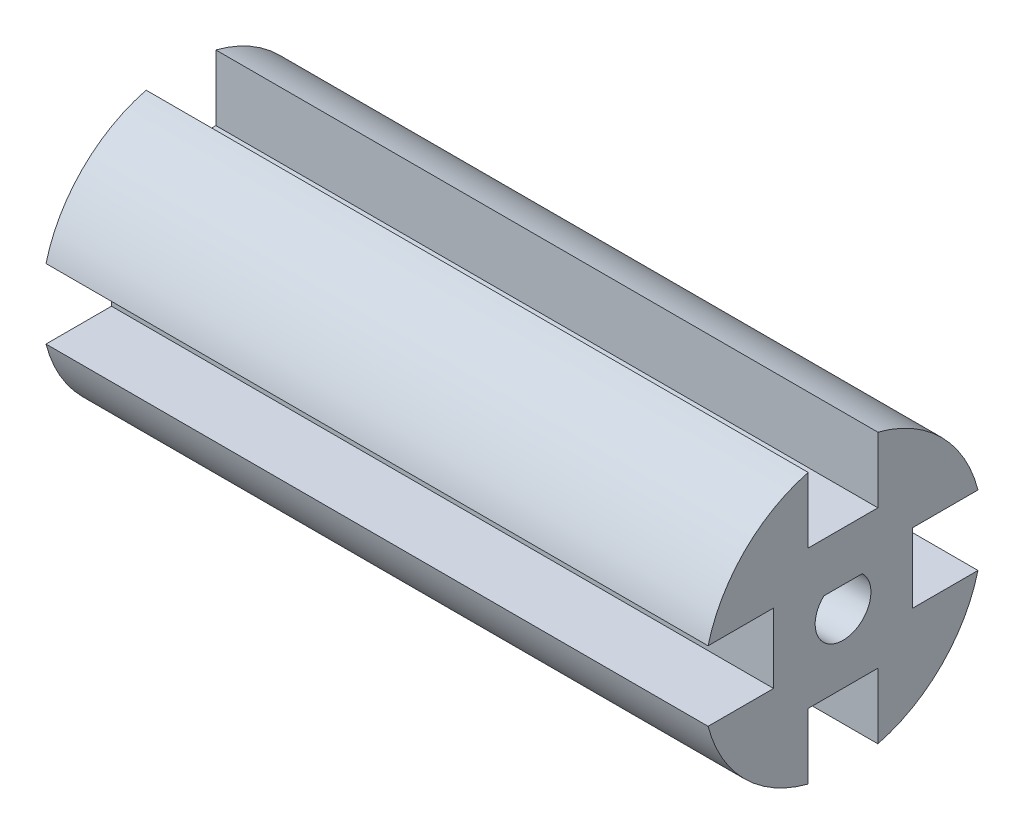
from build123d import *

# Parameters (mm, degrees)
EXTRUDED_CONNECTOR_DEPTH = 95
KEY_CUT_DEPTH            = 20


with BuildPart() as part:
    # Sketch1 → Extruded Connector (new body)
    with BuildSketch(Plane(origin=(0, 0, 0), x_dir=(0, 0, -1), z_dir=(1, 0, 0))):
        with BuildLine():
            ThreePointArc((-19.364916731, -5), (-14.142135624, -14.142135624), (-5, -19.364916731))
            Line((-5, -19.364916731), (-5, -9.964916731))
            Line((-5, -9.964916731), (5, -9.964916731))
            Line((5, -9.964916731), (5, -19.364916731))
            ThreePointArc((5, -19.364916731), (14.142135624, -14.142135624), (19.364916731, -5))
            Line((19.364916731, -5), (9.964916731, -5))
            Line((9.964916731, -5), (9.964916731, 5))
            Line((9.964916731, 5), (19.364916731, 5))
            ThreePointArc((19.364916731, 5), (14.142135624, 14.142135624), (5, 19.364916731))
            Line((5, 19.364916731), (5, 9.964916731))
            Line((5, 9.964916731), (-5, 9.964916731))
            Line((-5, 9.964916731), (-5, 19.364916731))
            ThreePointArc((-5, 19.364916731), (-14.142135624, 14.142135624), (-19.364916731, 5))
            Line((-19.364916731, 5), (-9.964916731, 5))
            Line((-9.964916731, 5), (-9.964916731, -5))
            Line((-9.964916731, -5), (-19.364916731, -5))
        make_face()
    extrude(amount=EXTRUDED_CONNECTOR_DEPTH)

    # Sketch2 → Key Cut (cut)
    with BuildSketch(Plane(origin=(95, 0, 0), x_dir=(0, 0, -1), z_dir=(1, 0, 0))):
        with BuildLine():
            Line((2.754995463, 2.9), (-2.754995463, 2.9))
            ThreePointArc((-2.754995463, 2.9), (-1.577976259, -3.675593955), (4, 0))
            ThreePointArc((4, 0), (3.675593955, 1.577976259), (2.754995463, 2.9))
        make_face()
    extrude(amount=-KEY_CUT_DEPTH, mode=Mode.SUBTRACT)


solid = part.part
